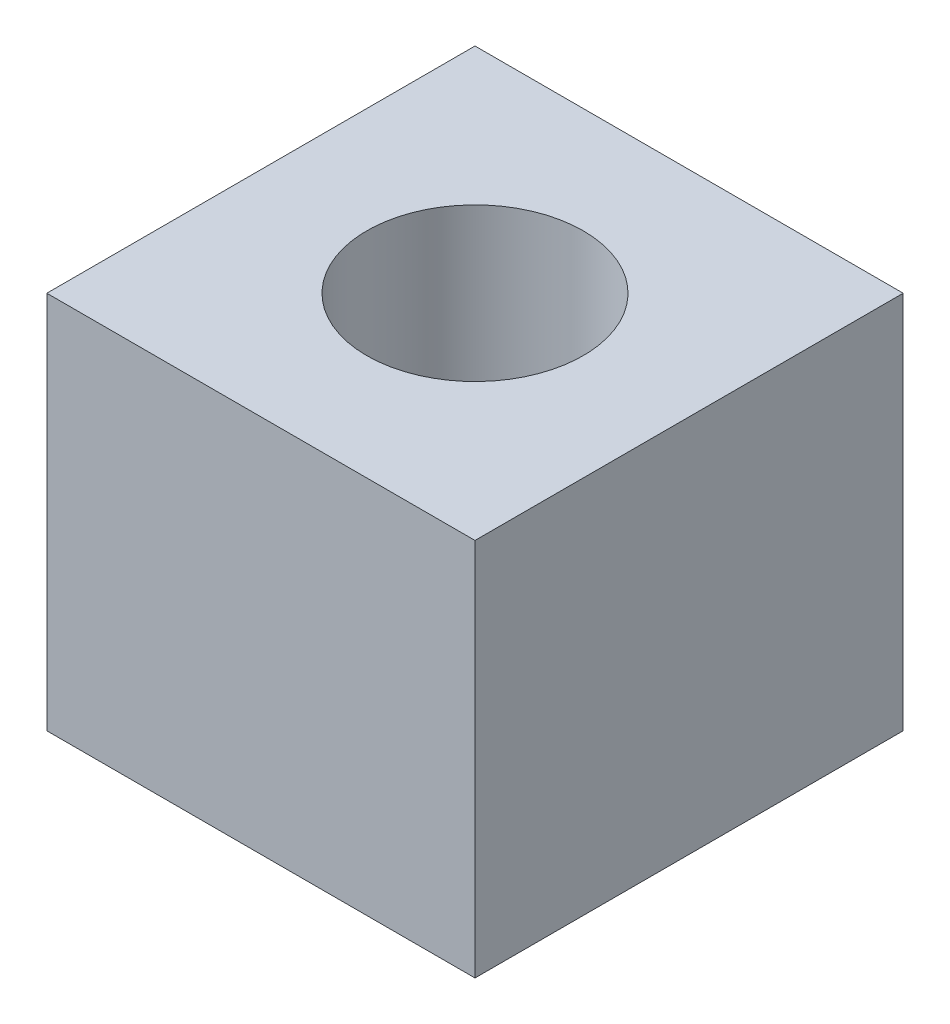
from build123d import *

# Parameters (mm, degrees)
SKETCH1_W           = 10
SKETCH1_H           = 10
BOSS_EXTRUDE1_DEPTH = 8.85
SKETCH2_R           = 2.5273
CUT_EXTRUDE1_DEPTH  = 4


with BuildPart() as part:
    # Sketch1 → Boss-Extrude1 (new body)
    with BuildSketch(Plane(origin=(0, 0, 0), x_dir=(1, 0, 0), z_dir=(0, 1, 0))):
        with Locations((5, 5)):
            Rectangle(SKETCH1_W, SKETCH1_H)
    extrude(amount=BOSS_EXTRUDE1_DEPTH)

    # Sketch2 → Cut-Extrude1 (cut)
    with BuildSketch(Plane(origin=(0, 8.85, 0), x_dir=(1, 0, 0), z_dir=(0, 1, 0))):
        with Locations((5, 5)):
            Circle(SKETCH2_R)
    extrude(amount=-CUT_EXTRUDE1_DEPTH, mode=Mode.SUBTRACT)


solid = part.part
